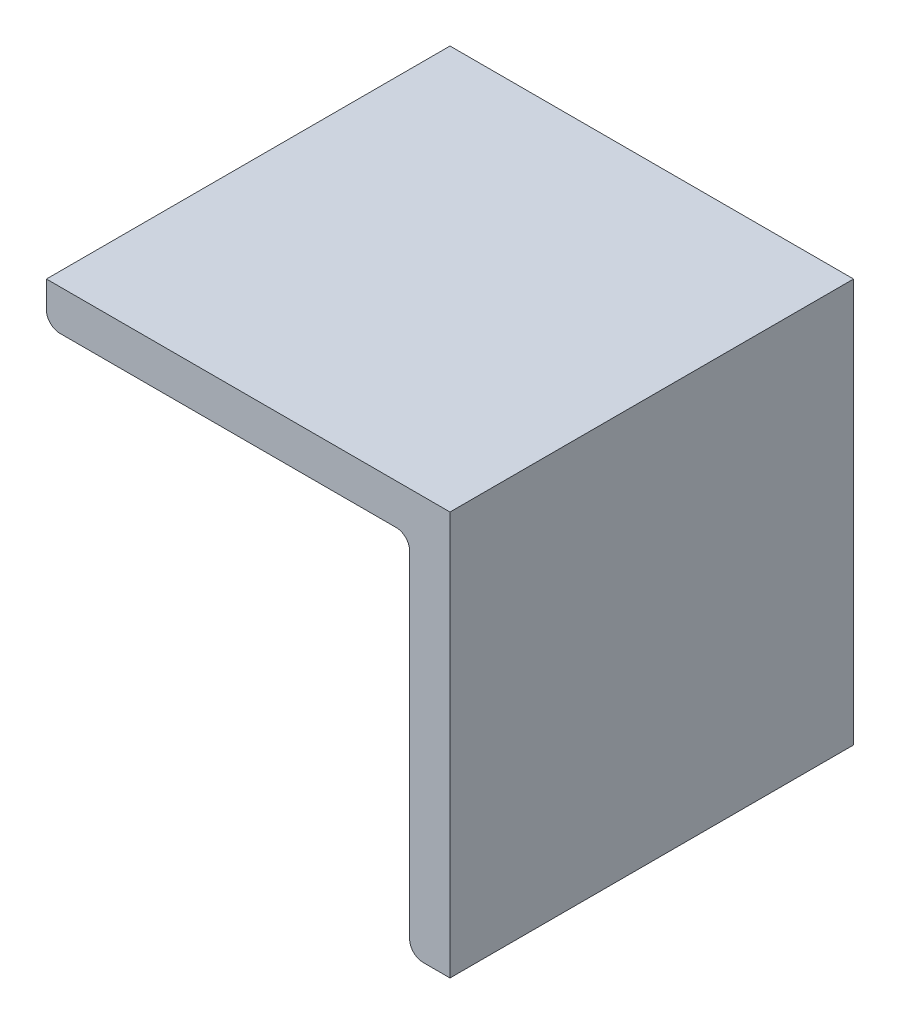
from build123d import *

# Parameters (mm, degrees)
EXTRUDE1_DEPTH = 30
FILLET1_R      = 1


with BuildPart() as part:
    # Sketch1 → Extrude1 (new body)
    with BuildSketch(Plane.XY):
        Polygon((0, 0), (-30, 0), (-30, -3), (-3, -3), (-3, -30), (0, -30), align=None)
    extrude(amount=EXTRUDE1_DEPTH)

    # Fillet1
    fillet1_edges = [part.edges().sort_by_distance(p)[0] for p in [
        (-3, -30, 15),
        (-3, -3, 15),
        (-30, -3, 15),
    ]]
    fillet(fillet1_edges, radius=FILLET1_R)


solid = part.part
